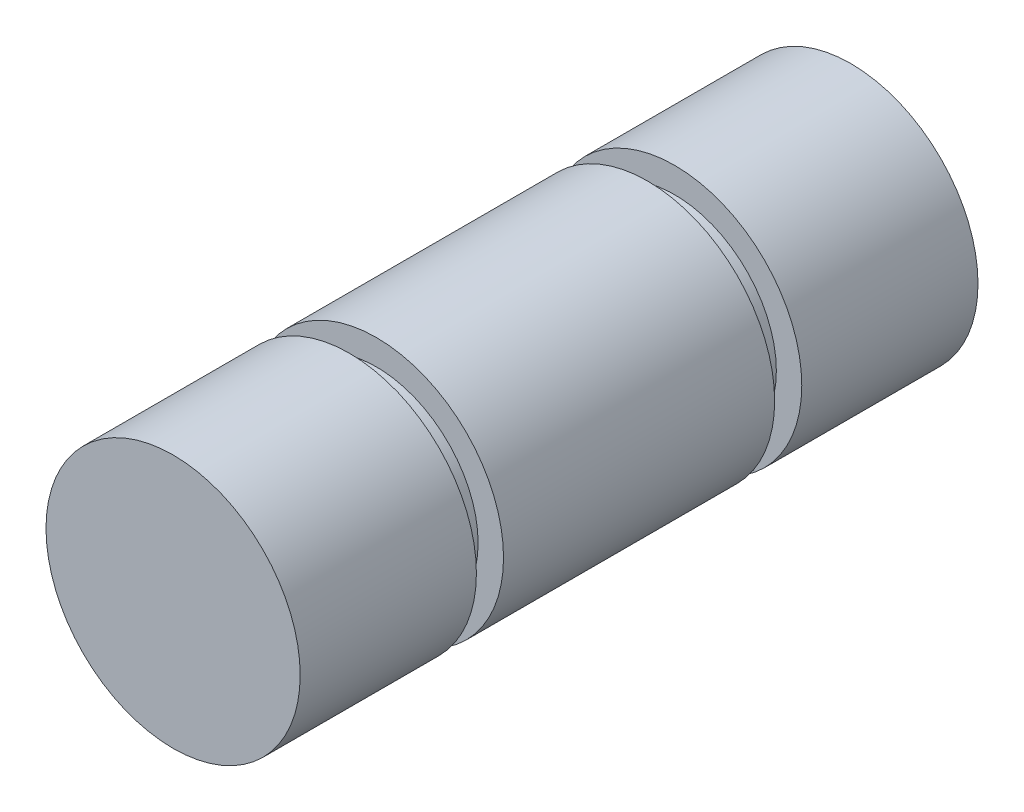
from build123d import *

# Parameters (mm, degrees)
SKETCH1_R           = 4.7625
BOSS_EXTRUDE1_DEPTH = 12.7
SKETCH2_W           = 0.9525
SKETCH2_H           = 1.016


with BuildPart() as part:
    # Sketch1 → Boss-Extrude1 (new body, symmetric)
    with BuildSketch(Plane.XY):
        Circle(SKETCH1_R)
    extrude(amount=BOSS_EXTRUDE1_DEPTH, both=True)

    # Sketch2 → Cut-Revolve1 (revolve, cut)
    with BuildSketch(Plane(origin=(0, 0, 0), x_dir=(1, 0, 0), z_dir=(0, 1, 0))):
        with Locations((4.28625, 5.588)):
            Rectangle(SKETCH2_W, SKETCH2_H)
        with Locations((4.28625, -5.588)):
            Rectangle(SKETCH2_W, SKETCH2_H)
    revolve(axis=Axis((0, 0, 12.7), (0, 0, -1)), mode=Mode.SUBTRACT)


solid = part.part
